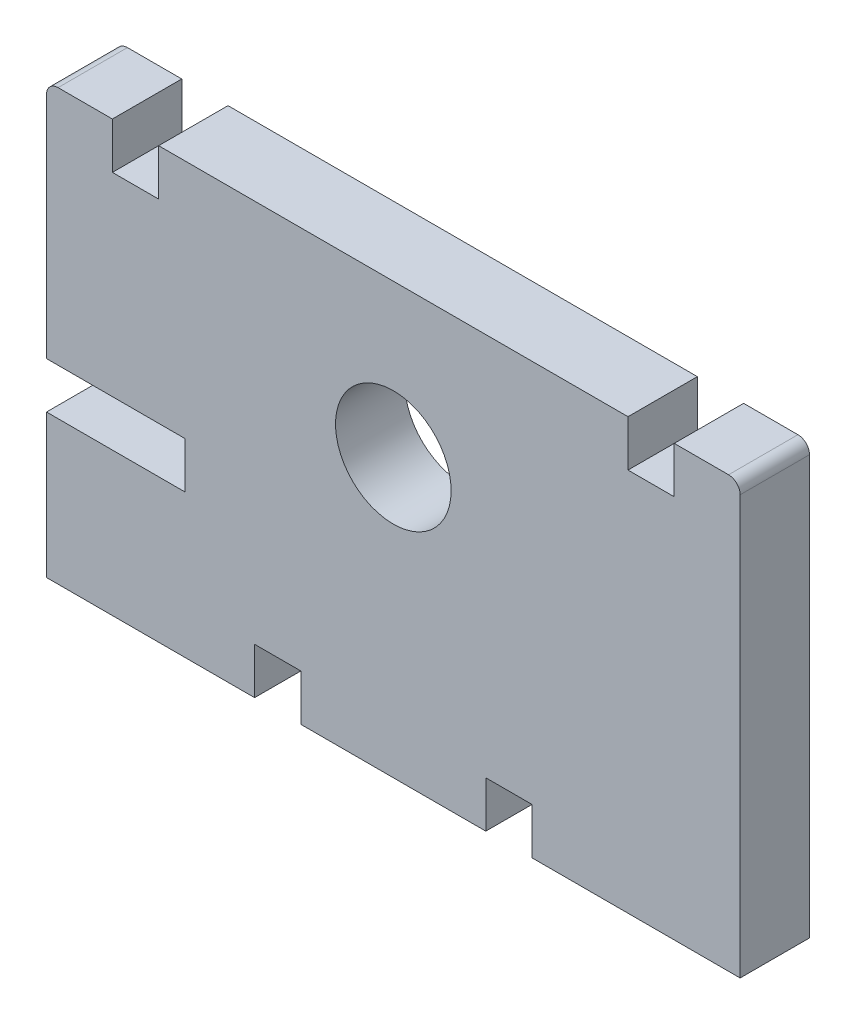
from build123d import *

# Parameters (mm, degrees)
SKETCH_1_R      = 2.5
EXTRUDE_1_DEPTH = 3
FILLET_1_R      = 0.5


with BuildPart() as part:
    # ｽｹｯﾁ1 → ﾎﾞｽ - 押し出し1 (new body)
    with BuildSketch(Plane.XY):
        Polygon((-12.15, 6.6), (-15, 6.6), (-15, -3.8), (-9, -3.8), (-9, -5.8), (-15, -5.8), (-15, -12), (-6, -12), (-6, -10), (-4, -10), (-4, -12), (4, -12), (4, -10), (6, -10), (6, -12), (15, -12), (15, 6.6), (12.15, 6.6), (12.15, 4.6), (10.15, 4.6), (10.15, 6.6), (-10.15, 6.6), (-10.15, 4.6), (-12.15, 4.6), align=None)
        Circle(SKETCH_1_R, mode=Mode.SUBTRACT)
    extrude(amount=EXTRUDE_1_DEPTH)

    # ﾌｨﾚｯﾄ1
    fillet_1_edges = [part.edges().sort_by_distance(p)[0] for p in [
        (-15, 6.6, 1.5),
        (15, 6.6, 1.5),
    ]]
    fillet(fillet_1_edges, radius=FILLET_1_R)


solid = part.part
